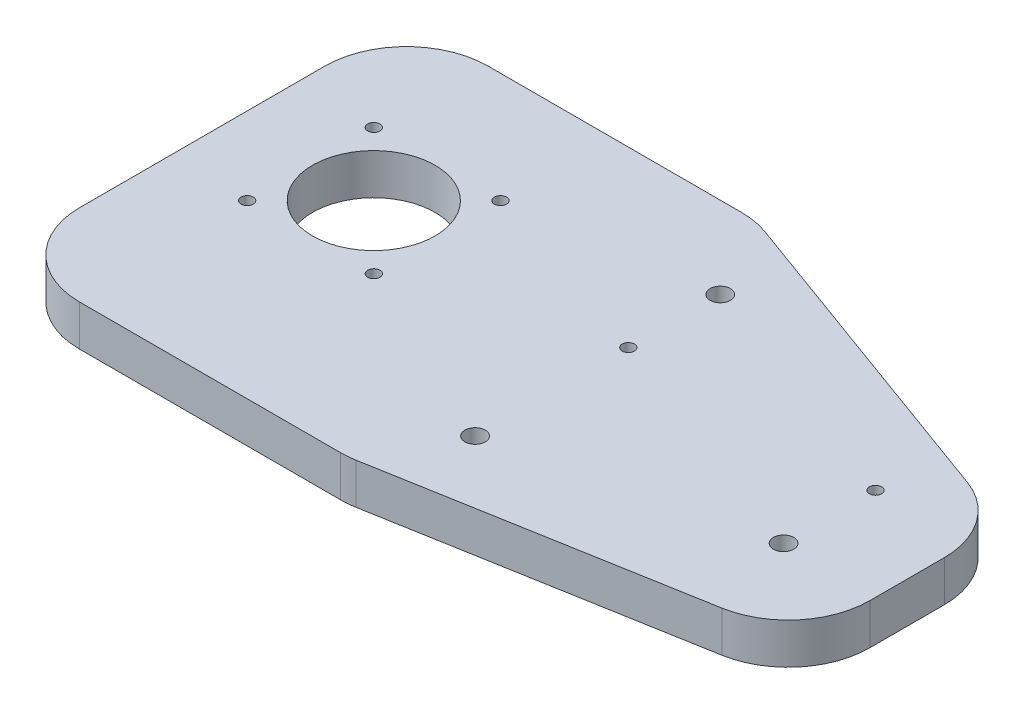
from build123d import *

# Parameters (mm, degrees)
SKETCH2_R           = 2.5
SKETCH2_R_2         = 15
SKETCH2_R_3         = 1.5
BOSS_EXTRUDE1_DEPTH = 10


with BuildPart() as part:
    # Sketch2 → Boss-Extrude1 (new body)
    with BuildSketch(Plane(origin=(0, 0, 0), x_dir=(1, 0, 0), z_dir=(0, 1, 0))):
        with BuildLine():
            Line((0, 20), (0, 80))
            ThreePointArc((0, 80), (5.857864376, 94.142135624), (20, 100))
            Line((20, 100), (82.080969389, 100))
            ThreePointArc((82.080969389, 100), (85.553932943, 99.69615506), (88.921372256, 98.793852416))
            Line((88.921372256, 98.793852416), (166.840402867, 70.433644591))
            ThreePointArc((166.840402867, 70.433644591), (176.383040886, 63.111320902), (180, 51.639792175))
            Line((180, 51.639792175), (180, 33.425935563))
            ThreePointArc((180, 33.425935563), (175.320888862, 20.570183369), (163.472963553, 13.729780502))
            Line((163.472963553, 13.729780502), (87.330699286, 0.30384494))
            ThreePointArc((87.330699286, 0.30384494), (85.600850588, 0.076106038), (83.857735733, 0))
            Line((83.857735733, 0), (20, 0))
            ThreePointArc((20, 0), (5.857864376, 5.857864376), (0, 20))
        make_face()
        with Locations((96.8, 80)):
            Circle(SKETCH2_R, mode=Mode.SUBTRACT)
        with Locations((96.8, 20)):
            Circle(SKETCH2_R, mode=Mode.SUBTRACT)
        with Locations((157.3, 35)):
            Circle(SKETCH2_R, mode=Mode.SUBTRACT)
        with Locations((34.5, 57.5)):
            Circle(SKETCH2_R_2, mode=Mode.SUBTRACT)
        with Locations((19, 73)):
            Circle(SKETCH2_R_3, mode=Mode.SUBTRACT)
        with Locations((50, 73)):
            Circle(SKETCH2_R_3, mode=Mode.SUBTRACT)
        with Locations((19, 42)):
            Circle(SKETCH2_R_3, mode=Mode.SUBTRACT)
        with Locations((50, 42)):
            Circle(SKETCH2_R_3, mode=Mode.SUBTRACT)
        with Locations((96.8, 57.5)):
            Circle(SKETCH2_R_3, mode=Mode.SUBTRACT)
        with Locations((157.3, 57.5)):
            Circle(SKETCH2_R_3, mode=Mode.SUBTRACT)
    extrude(amount=BOSS_EXTRUDE1_DEPTH)


solid = part.part
